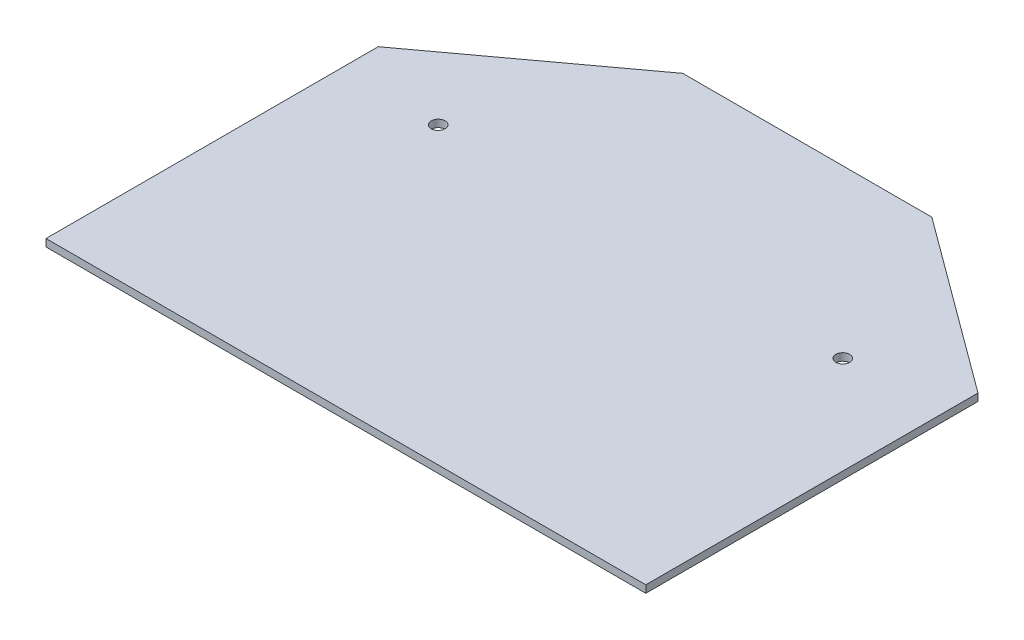
from build123d import *

# Parameters (mm, degrees)
SKETCH1_R           = 1.5
BOSS_EXTRUDE1_DEPTH = 1.6


with BuildPart() as part:
    # Sketch1 → Boss-Extrude1 (new body)
    with BuildSketch(Plane(origin=(0, 0, 0), x_dir=(1, 0, 0), z_dir=(0, 1, 0))):
        Polygon((-65, 52), (-27, 80), (0, 80), (0, -20), (-65, -20), align=None)
        with Locations((-43.840620434, 43.840620434)):
            Circle(SKETCH1_R, mode=Mode.SUBTRACT)
    boss_extrude1 = extrude(amount=BOSS_EXTRUDE1_DEPTH)

    # Mirror1: Boss-Extrude1 across plane
    add(boss_extrude1.mirror(Plane(origin=(0, 1.6, 20), x_dir=(0, 0, 1), z_dir=(-1, 0, 0))))


solid = part.part
